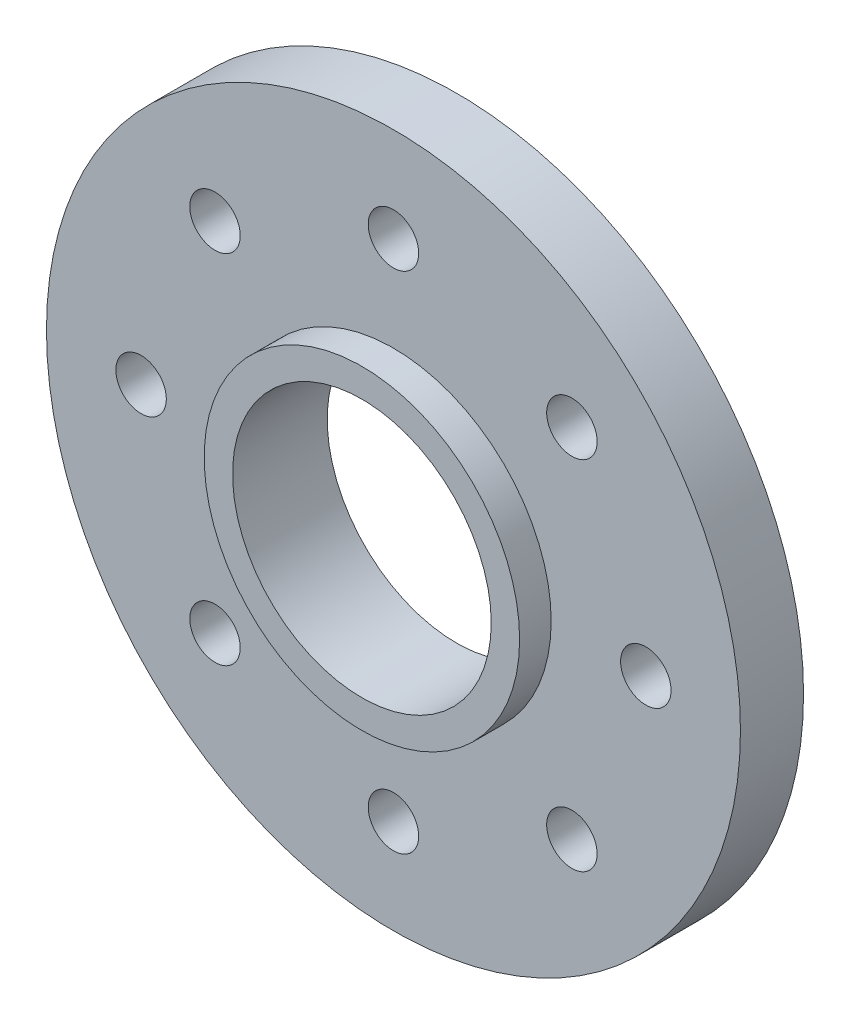
from build123d import *

# Parameters (mm, degrees)
SKETCH1_R                 = 11
SKETCH1_R_2               = 4.1
BOSS_EXTRUDE1_DEPTH       = 2
M2X0_4_TAPPED_HOLE1_D     = 1.6
M2X0_4_TAPPED_HOLE1_DEPTH = 5.2
M2X0_4_TAPPED_HOLE1_TIP   = 0.480688495
SKETCH5_R                 = 5
SKETCH5_R_2               = 4.1
BOSS_EXTRUDE2_DEPTH       = 1


with BuildPart() as part:
    # Sketch1 → Boss-Extrude1 (new body)
    with BuildSketch(Plane.XY):
        Circle(SKETCH1_R)
        Circle(SKETCH1_R_2, mode=Mode.SUBTRACT)
    extrude(amount=BOSS_EXTRUDE1_DEPTH)

    # M2x0.4 Tapped Hole1
    with Locations(Plane.XY.offset(2)):
        with Locations((0, 8), (5.656854249, 5.656854249), (8, 0), (5.656854249, -5.656854249), (0, -8), (-5.656854249, -5.656854249), (-8, 0), (-5.656854249, 5.656854249)):
            Hole(M2X0_4_TAPPED_HOLE1_D / 2, depth=M2X0_4_TAPPED_HOLE1_DEPTH)
            with Locations((0, 0, -(M2X0_4_TAPPED_HOLE1_DEPTH + M2X0_4_TAPPED_HOLE1_TIP / 2))):  # 118° drill point
                Cone(0, M2X0_4_TAPPED_HOLE1_D / 2, M2X0_4_TAPPED_HOLE1_TIP, mode=Mode.SUBTRACT)

    # Sketch5 → Boss-Extrude2 (add)
    with BuildSketch(Plane.XY.offset(2)):
        Circle(SKETCH5_R)
        Circle(SKETCH5_R_2, mode=Mode.SUBTRACT)
    extrude(amount=BOSS_EXTRUDE2_DEPTH)


solid = part.part
